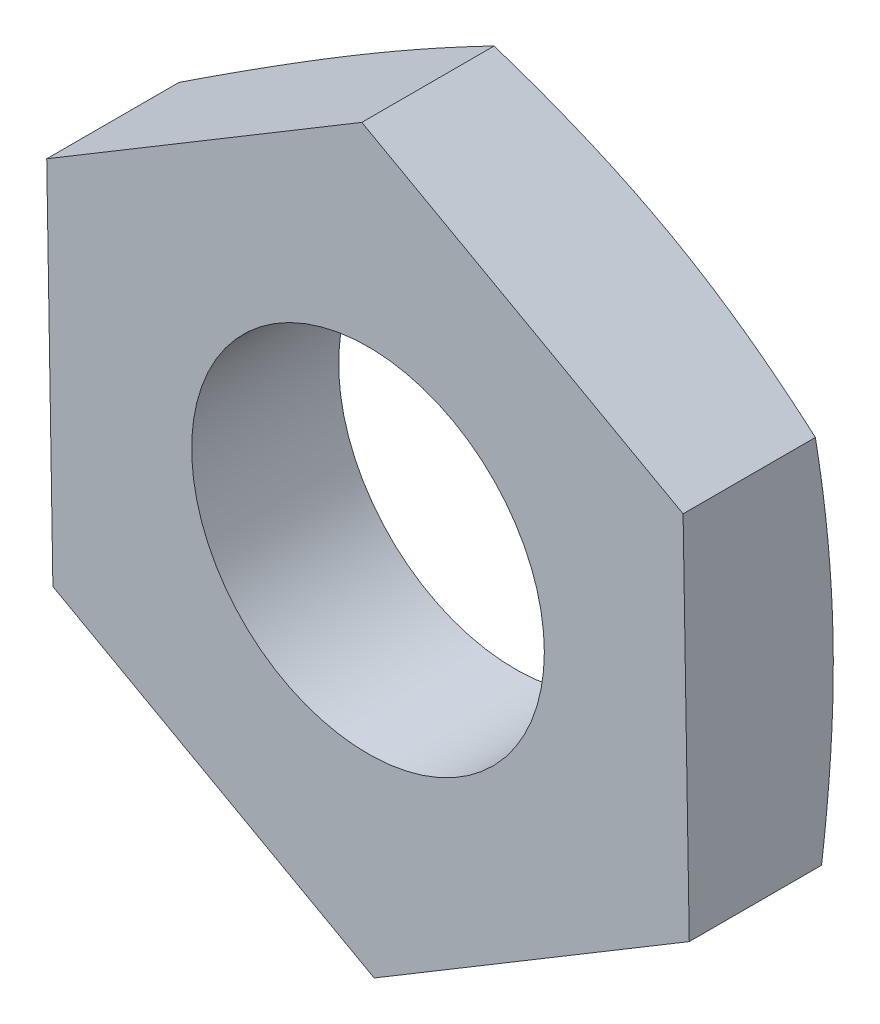
from build123d import *

# Parameters (mm, degrees)
SKETCH1_R           = 6
BOSS_EXTRUDE1_DEPTH = 5


with BuildPart() as part:
    # Sketch1 → Boss-Extrude1 (new body)
    with BuildSketch(Plane.XY):
        Polygon((-12.885241611, 7.406445139), (-1.954784619, 1.338552), (8.765393483, 7.770658861), (8.555114593, 20.270658861), (-2.3753424, 26.338552), (-13.095520502, 19.906445139), align=None)
        with Locations((-2.165063509, 13.838552)):
            Circle(SKETCH1_R, mode=Mode.SUBTRACT)
    extrude(amount=BOSS_EXTRUDE1_DEPTH)

    # Sketch4 → Cut-Revolve2 (revolve, cut)
    with BuildSketch(Plane(origin=(5.363371252, 9.661359793, 0), x_dir=(0.874312857, -0.48536278, 0), z_dir=(0.48536278, 0.874312857, 0))):
        Polygon((-19.434660926, 0), (-21.111429489, -0.5), (-21.548582722, -0.5), (-21.548582722, 0.495930671), (-19.434660926, 0.495930671), align=None)
    revolve(axis=Axis((-2.164165992, 13.840168751, 0), (0, 0, 1)), mode=Mode.SUBTRACT)


solid = part.part
